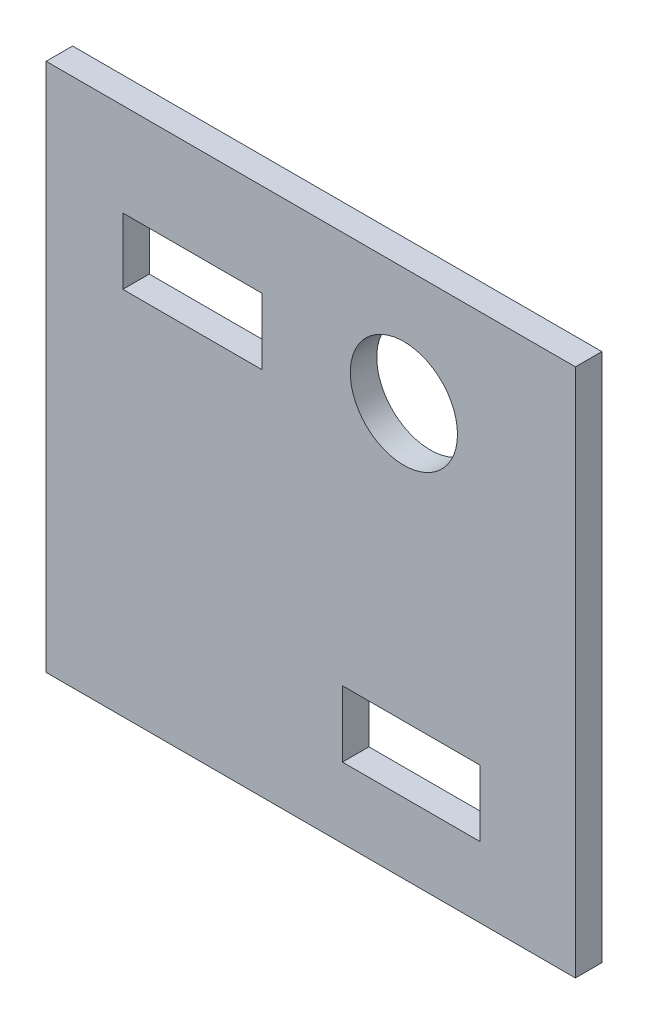
from build123d import *

# Parameters (mm, degrees)
SKETCH1_W           = 40
SKETCH1_H           = 40
BOSS_EXTRUDE1_DEPTH = 2
SKETCH2_R           = 4.051209194
SKETCH2_W           = 10.5
SKETCH2_H           = 5
SKETCH2_W_2         = 10.4
CUT_EXTRUDE1_DEPTH  = 2


with BuildPart() as part:
    # Sketch1 → Boss-Extrude1 (new body)
    with BuildSketch(Plane.XY):
        with Locations((2.604651163, -5.348837209)):
            Rectangle(SKETCH1_W, SKETCH1_H)
    extrude(amount=BOSS_EXTRUDE1_DEPTH)

    # Sketch2 → Cut-Extrude1 (cut)
    with BuildSketch(Plane.XY.offset(2)):
        with Locations((9.640879808, 5.775039394)):
            Circle(SKETCH2_R)
        with Locations((-6.349639686, 5.122249596)):
            Rectangle(SKETCH2_W, SKETCH2_H)
        with Locations((10.198633094, -17.522169699)):
            Rectangle(SKETCH2_W_2, SKETCH2_H)
    extrude(amount=-CUT_EXTRUDE1_DEPTH, mode=Mode.SUBTRACT)


solid = part.part
